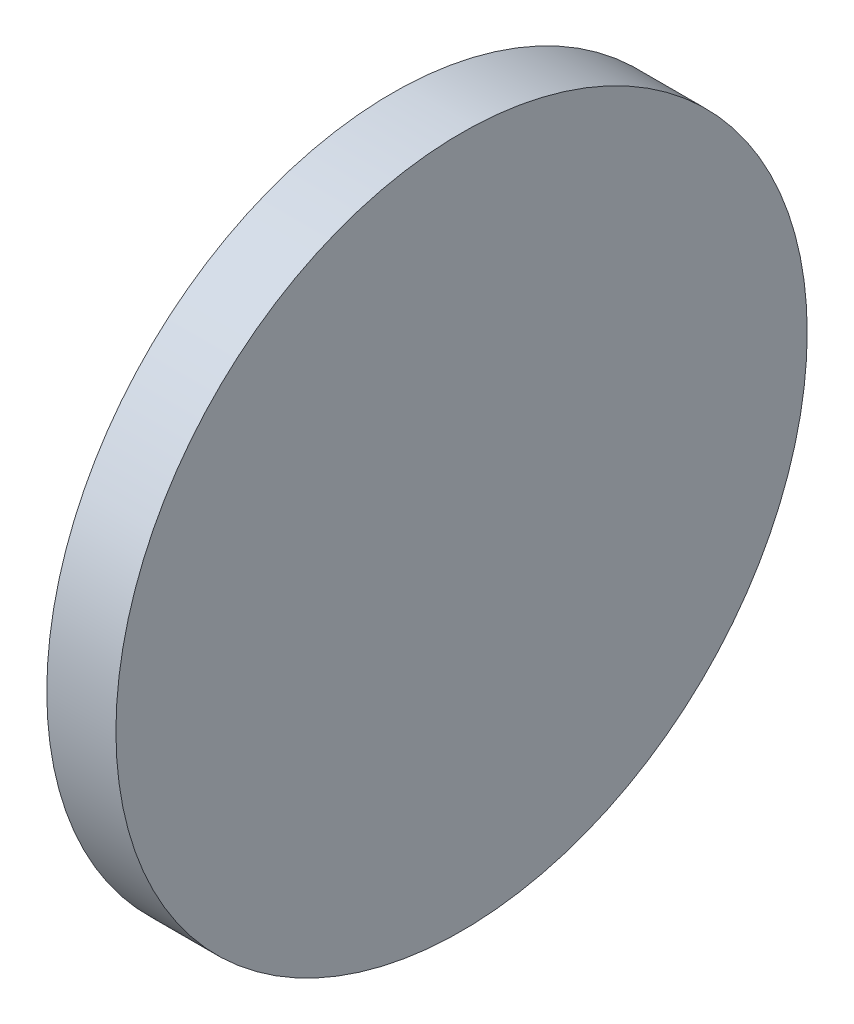
from build123d import *

# Parameters (mm, degrees)
SKETCH_1_W = 2
SKETCH_1_H = 10


with BuildPart() as part:
    # 草图1 → 旋转1 (revolve)
    with BuildSketch(Plane.XY, mode=Mode.PRIVATE) as revolve_1_sk:
        with Locations((174.418664707, 56.528786233)):
            Rectangle(SKETCH_1_W, SKETCH_1_H)
    revolve(revolve_1_sk.sketch.rotate(Axis((169.333867995, 51.528786233, 0), (1, 0, 0)), 90), axis=Axis((169.333867995, 51.528786233, 0), (1, 0, 0)))  # turned: the seam where the file's is


solid = part.part
